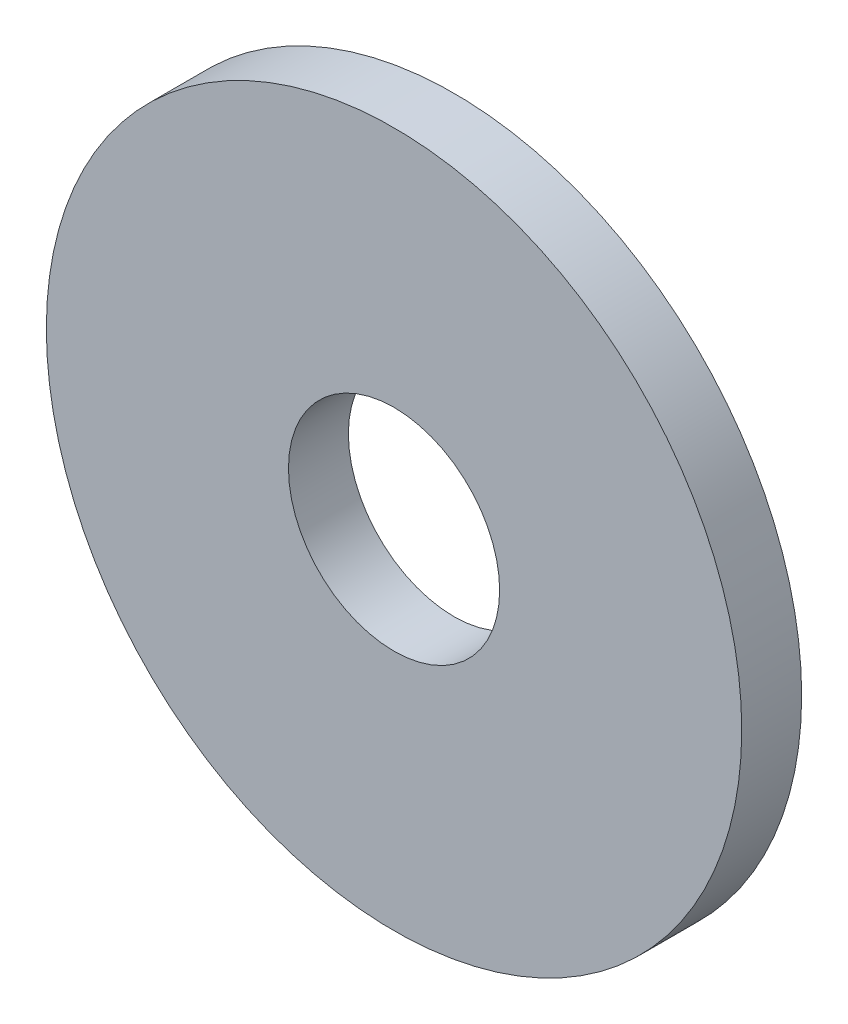
from build123d import *

# Parameters (mm, degrees)
SKETCH1_R           = 7.08
SKETCH1_R_2         = 2.15
BOSS_EXTRUDE1_DEPTH = 0.61


with BuildPart() as part:
    # Sketch1 → Boss-Extrude1 (new body, symmetric)
    with BuildSketch(Plane.XY):
        Circle(SKETCH1_R)
        Circle(SKETCH1_R_2, mode=Mode.SUBTRACT)
    extrude(amount=BOSS_EXTRUDE1_DEPTH, both=True)


solid = part.part
